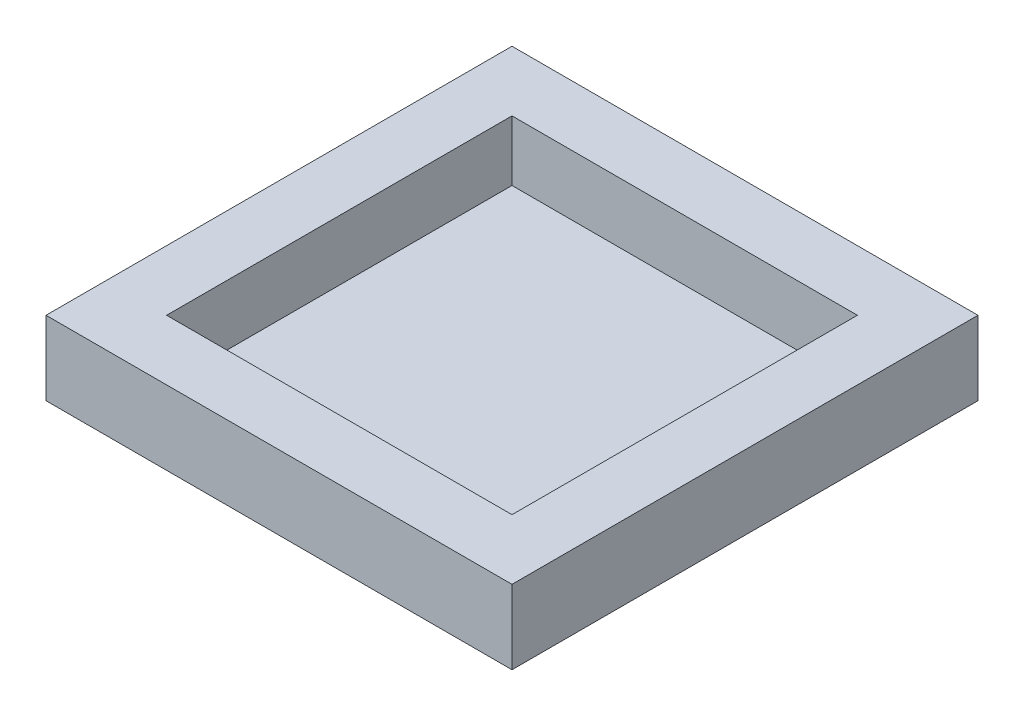
from build123d import *

# Parameters (mm, degrees)
ESQUISSE1_W      = 170
ESQUISSE1_H      = 170
EXTRUSION1_DEPTH = 5
ESQUISSE2_W      = 170
ESQUISSE2_H      = 170
ESQUISSE2_W_2    = 126
ESQUISSE2_H_2    = 126
EXTRUSION2_DEPTH = 22


with BuildPart() as part:
    # Esquisse1 → Extrusion1 (new body)
    with BuildSketch(Plane(origin=(0, 0, 0), x_dir=(1, 0, 0), z_dir=(0, 1, 0))):
        with Locations((85, 85)):
            Rectangle(ESQUISSE1_W, ESQUISSE1_H)
    extrude(amount=EXTRUSION1_DEPTH)

    # Esquisse2 → Extrusion2 (add)
    with BuildSketch(Plane(origin=(0, 5, 0), x_dir=(-1, 0, 0), z_dir=(0, 1, 0))):
        with Locations((-85, -85)):
            Rectangle(ESQUISSE2_W, ESQUISSE2_H)
        with Locations((-85, -85)):
            Rectangle(ESQUISSE2_W_2, ESQUISSE2_H_2, mode=Mode.SUBTRACT)
    extrude(amount=EXTRUSION2_DEPTH)


solid = part.part
